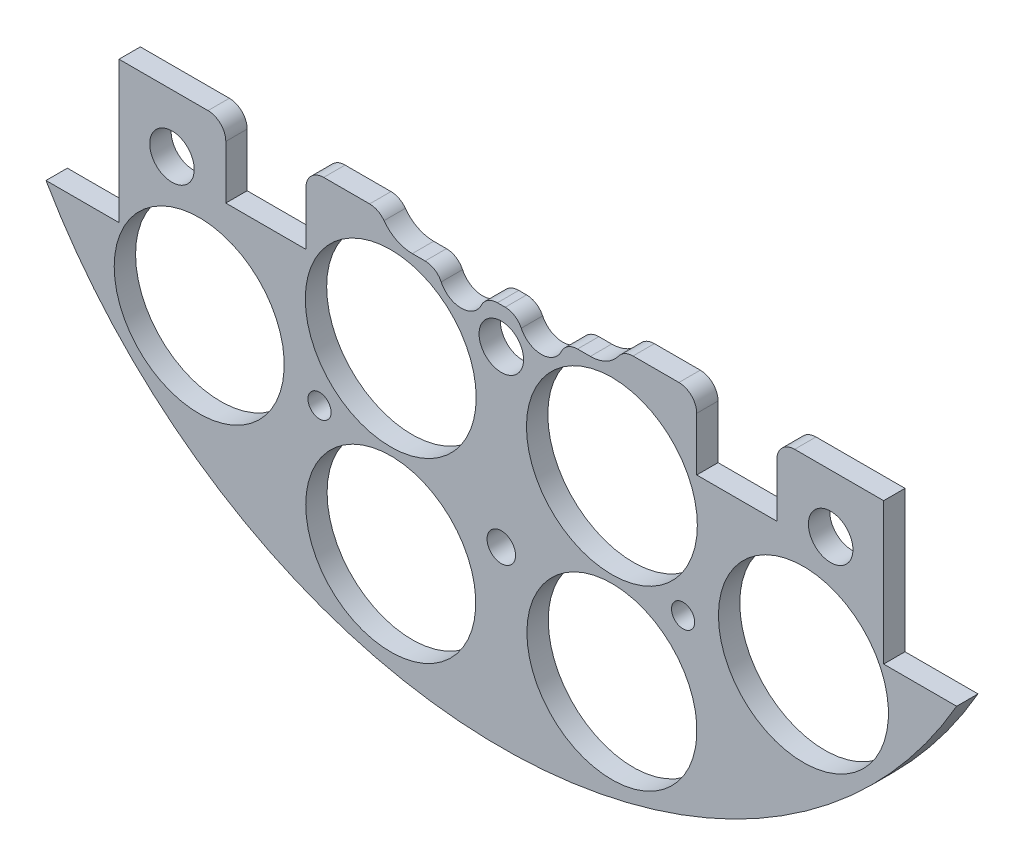
from build123d import *

# Parameters (mm, degrees)
SKETCH1_R                 = 1.651
BOSS_EXTRUDE2_DEPTH       = 3.048
SKETCH2_R                 = 1.143
CUT_EXTRUDE1_DEPTH        = 4.048
SKETCH3_R                 = 12.1285
CUT_EXTRUDE2_DEPTH        = 4.048
SKETCH4_W                 = 28.562713242
SKETCH4_H                 = 11.677503754
BOSS_EXTRUDE3_DEPTH       = 3.048
SKETCH5_W                 = 216.7214489
SKETCH5_H                 = 130.569220634
CUT_EXTRUDE4_DEPTH        = 4.048
SKETCH6_W                 = 4.7625
SKETCH6_H                 = 27.432
CUT_EXTRUDE5_DEPTH        = 4.048
SKETCH10_W                = 11.43
SKETCH10_H                = 10.16
CUT_EXTRUDE9_DEPTH        = 4.048
FILLET1_R                 = 6
FILLET2_R                 = 6
SKETCH66_R                = 1.651
CUT_EXTRUDE65_DEPTH       = 97.79
SKETCH120_R               = 3.175
CUT_EXTRUDE119_DEPTH      = 103.378
CUT_EXTRUDE119_DEPTH_BACK = 48.768
CUT_EXTRUDE12_DEPTH       = 10
FILLET3_R                 = 2.54
BOSS_EXTRUDE4_DEPTH       = 3.048
SKETCH122_R               = 2.032
CUT_EXTRUDE120_DEPTH      = 27.305
SKETCH123_R               = 12.192
CUT_EXTRUDE121_DEPTH      = 19.05


with BuildPart() as part:
    # Sketch1 → Boss-Extrude2 (new body)
    with BuildSketch(Plane.XY):
        with BuildLine():
            Line((-64.964441474, 37.338), (-54.550441474, 37.338))
            Line((-54.550441474, 37.338), (-54.550441474, -37.338))
            Line((-54.550441474, -37.338), (-64.964441474, -37.338))
            ThreePointArc((-64.964441474, -37.338), (0, -74.93), (64.964441474, -37.338))
            Line((64.964441474, -37.338), (54.550441474, -37.338))
            Line((54.550441474, -37.338), (54.550441474, 37.338))
            Line((54.550441474, 37.338), (64.964441474, 37.338))
            ThreePointArc((64.964441474, 37.338), (0, 74.93), (-64.964441474, 37.338))
        make_face()
        with Locations((-46.482, 11.049)):
            Circle(SKETCH1_R, mode=Mode.SUBTRACT)
        with Locations((-21.083270032, 10.795)):
            Circle(SKETCH1_R, mode=Mode.SUBTRACT)
        with Locations((-21.083270032, -10.795)):
            Circle(SKETCH1_R, mode=Mode.SUBTRACT)
        with Locations((-46.482, -11.049)):
            Circle(SKETCH1_R, mode=Mode.SUBTRACT)
        with Locations((46.482, -11.049)):
            Circle(SKETCH1_R, mode=Mode.SUBTRACT)
        with Locations((21.083270032, -10.795)):
            Circle(SKETCH1_R, mode=Mode.SUBTRACT)
        with Locations((21.083270032, 10.795)):
            Circle(SKETCH1_R, mode=Mode.SUBTRACT)
        with Locations((46.482, 11.049)):
            Circle(SKETCH1_R, mode=Mode.SUBTRACT)
    extrude(amount=BOSS_EXTRUDE2_DEPTH)

    # Sketch2 → Cut-Extrude1 (cut, through all)
    with BuildSketch(Plane.XY.offset(3.048)):
        with Locations((-6.731, 62.23)):
            Circle(SKETCH2_R)
        with Locations((6.731, 62.23)):
            Circle(SKETCH2_R)
    extrude(amount=-CUT_EXTRUDE1_DEPTH, mode=Mode.SUBTRACT)

    # Sketch3 → Cut-Extrude2 (cut, through all)
    with BuildSketch(Plane(origin=(0, 0, 0), x_dir=(-1, 0, 0), z_dir=(0, 0, -1))):
        with Locations((-15.777608989, -58.882838371)):
            Circle(SKETCH3_R)
        with Locations((15.777608989, -58.882838371)):
            Circle(SKETCH3_R)
        with Locations((-43.105229381, -43.105229381)):
            Circle(SKETCH3_R)
        with Locations((19.05, 32.995567884)):
            Circle(SKETCH3_R)
        with Locations((-43.105229381, 43.105229381)):
            Circle(SKETCH3_R)
        with Locations((43.105229381, 43.105229381)):
            Circle(SKETCH3_R)
        with Locations((-19.05, 32.995567884)):
            Circle(SKETCH3_R)
        with Locations((43.105229381, -43.105229381)):
            Circle(SKETCH3_R)
    extrude(amount=-CUT_EXTRUDE2_DEPTH, mode=Mode.SUBTRACT)

    # Sketch4 → Boss-Extrude3 (add)
    with BuildSketch(Plane(origin=(0, 0, 0), x_dir=(-1, 0, 0), z_dir=(0, 0, -1))):
        with Locations((-1.488809975, 62.152540216)):
            Rectangle(SKETCH4_W, SKETCH4_H)
    extrude(amount=-BOSS_EXTRUDE3_DEPTH)

    # Sketch5 → Cut-Extrude4 (cut, through all)
    with BuildSketch(Plane(origin=(0, 0, 0), x_dir=(-1, 0, 0), z_dir=(0, 0, -1))):
        with Locations((23.316688373, 48.139610317)):
            Rectangle(SKETCH5_W, SKETCH5_H)
    extrude(amount=-CUT_EXTRUDE4_DEPTH, mode=Mode.SUBTRACT)

    # Sketch6 → Cut-Extrude5 (cut, through all)
    with BuildSketch(Plane(origin=(0, 0, 0), x_dir=(-1, 0, 0), z_dir=(0, 0, -1))):
        with Locations((0, -45.847)):
            Rectangle(SKETCH6_W, SKETCH6_H)
        Polygon((-2.38125, -34.131), (-2.38125, -32.131), (-6.38125, -32.131), (-6.38125, -17.145), (-9.38125, -17.145), (-9.38125, -34.131), align=None)
    extrude(amount=-CUT_EXTRUDE5_DEPTH, mode=Mode.SUBTRACT)

    # Sketch10 → Cut-Extrude9 (cut, through all)
    with BuildSketch(Plane(origin=(0, 0, 0), x_dir=(-1, 0, 0), z_dir=(0, 0, -1))):
        with Locations((-33.595441474, -22.225)):
            Rectangle(SKETCH10_W, SKETCH10_H)
        with Locations((33.595441474, -22.225)):
            Rectangle(SKETCH10_W, SKETCH10_H)
    extrude(amount=-CUT_EXTRUDE9_DEPTH, mode=Mode.SUBTRACT)

    # Fillet1
    fillet1_edges = [part.edges().sort_by_distance(p)[0] for p in [
        (6.38125, -32.131, 1.524),
    ]]
    fillet(fillet1_edges, radius=FILLET1_R)

    # Fillet2
    fillet2_edges = [part.edges().sort_by_distance(p)[0] for p in [
        (2.38125, -34.131, 1.524),
    ]]
    fillet(fillet2_edges, radius=FILLET2_R)

    # Sketch66 → Cut-Extrude65 (cut)
    with BuildSketch(Plane(origin=(30.092005081, 4.08352975, -16.1925), x_dir=(-1, 0, 0), z_dir=(0, 0, -1))):
        with Locations((4.154396091, -49.728759131)):
            Circle(SKETCH66_R)
        with Locations((56.02961407, -49.728759131)):
            Circle(SKETCH66_R)
    extrude(amount=-CUT_EXTRUDE65_DEPTH, mode=Mode.SUBTRACT)

    # Sketch120 → Cut-Extrude119 (cut, two sides)
    with BuildSketch(Plane(origin=(30.092005081, 4.08352975, 19.939), x_dir=(-1, 0, 0), z_dir=(0, 0, -1))) as cut_extrude119_sk:
        with Locations((77.082005081, -29.48352975)):
            Circle(SKETCH120_R)
        with Locations((30.092005081, -29.48352975)):
            Circle(SKETCH120_R)
        with Locations((-16.897994919, -29.48352975)):
            Circle(SKETCH120_R)
    extrude(amount=CUT_EXTRUDE119_DEPTH, mode=Mode.SUBTRACT)
    extrude(cut_extrude119_sk.sketch, amount=-CUT_EXTRUDE119_DEPTH_BACK, mode=Mode.SUBTRACT)

    # Sketch13 → Cut-Extrude12 (cut)
    with BuildSketch(Plane(origin=(0, 0, 0), x_dir=(-1, 0, 0), z_dir=(0, 0, -1))):
        with BuildLine():
            Line((-12.7, -20.24), (-8.888991966, -20.24))
            ThreePointArc((-8.888991966, -20.24), (-5.715, -23.495), (-2.541008034, -20.24))
            Line((-2.541008034, -20.24), (2.541008034, -20.24))
            ThreePointArc((2.541008034, -20.24), (5.715, -23.495), (8.888991966, -20.24))
            Line((8.888991966, -20.24), (12.7, -20.24))
            ThreePointArc((12.7, -20.24), (16.235533906, -11.704466094), (7.7, -15.24))
            Line((7.7, -15.24), (-1.0625, -15.24))
            ThreePointArc((-1.0625, -15.24), (-4.012347567, -10.679640913), (-9.38125, -11.500227489))
            ThreePointArc((-9.38125, -11.500227489), (-17.374337523, -13.465015853), (-12.7, -20.24))
        make_face()
    extrude(amount=-CUT_EXTRUDE12_DEPTH, mode=Mode.SUBTRACT)

    # Fillet3
    fillet3_edges = [part.edges().sort_by_distance(p)[0] for p in [
        (39.310441474, -17.145, 1.524),
        (27.880441474, -17.145, 1.524),
        (-27.880441474, -17.145, 1.524),
        (-39.310441474, -17.145, 1.524),
        (6.38125, -23.424309253, 1.524),
        (9.38125, -20.24, 1.524),
        (17.322875188, -17.145, 1.524),
        (-17.322875188, -17.145, 1.524),
        (-8.888991966, -20.24, 1.524),
        (-2.541008034, -20.24, 1.524),
        (2.541008034, -20.24, 1.524),
    ]]
    fillet(fillet3_edges, radius=FILLET3_R)

    # Sketch121 → Boss-Extrude4 (add)
    with BuildSketch(Plane.XY.offset(3.048)):
        with BuildLine():
            Line((2.891074229, -60.515426156), (4.322679041, -42.124810499))
            Line((4.322679041, -42.124810499), (14.013542381, -30.56184856))
            Line((14.013542381, -30.56184856), (14.76082601, -20.962128091))
            Line((14.76082601, -20.962128091), (16.738759609, -18.187612732))
            ThreePointArc((16.738759609, -18.187612732), (14.965164049, -19.697469218), (12.7, -20.24))
            Line((12.7, -20.24), (10.873451803, -20.24))
            ThreePointArc((10.873451803, -20.24), (9.5179937, -20.631900064), (8.580806557, -21.686666667))
            ThreePointArc((8.580806557, -21.686666667), (5.715, -23.495), (2.849193443, -21.686666667))
            Line((2.849193443, -21.686666667), (4.942864205, -26.845073773))
            Line((4.942864205, -26.845073773), (2.891074229, -29.631036754))
            Line((2.891074229, -29.631036754), (-4.156826382, -31.552959583))
            Line((-4.156826382, -31.552959583), (-2.945468464, -62.167277862))
            Line((-2.945468464, -62.167277862), (2.891074229, -60.515426156))
        make_face()
    extrude(amount=-BOSS_EXTRUDE4_DEPTH)

    # Sketch122 → Cut-Extrude120 (cut)
    with BuildSketch(Plane.XY.offset(3.048)):
        with Locations((0, -50.165)):
            Circle(SKETCH122_R)
    extrude(amount=-CUT_EXTRUDE120_DEPTH, mode=Mode.SUBTRACT)

    # Sketch123 → Cut-Extrude121 (cut)
    with BuildSketch(Plane(origin=(0, 0, 0), x_dir=(-1, 0, 0), z_dir=(0, 0, -1))):
        with Locations((-15.777608989, -33.482838371)):
            Circle(SKETCH123_R)
        with Locations((15.777608989, -33.482838371)):
            Circle(SKETCH123_R)
    extrude(amount=-CUT_EXTRUDE121_DEPTH, mode=Mode.SUBTRACT)


solid = part.part
